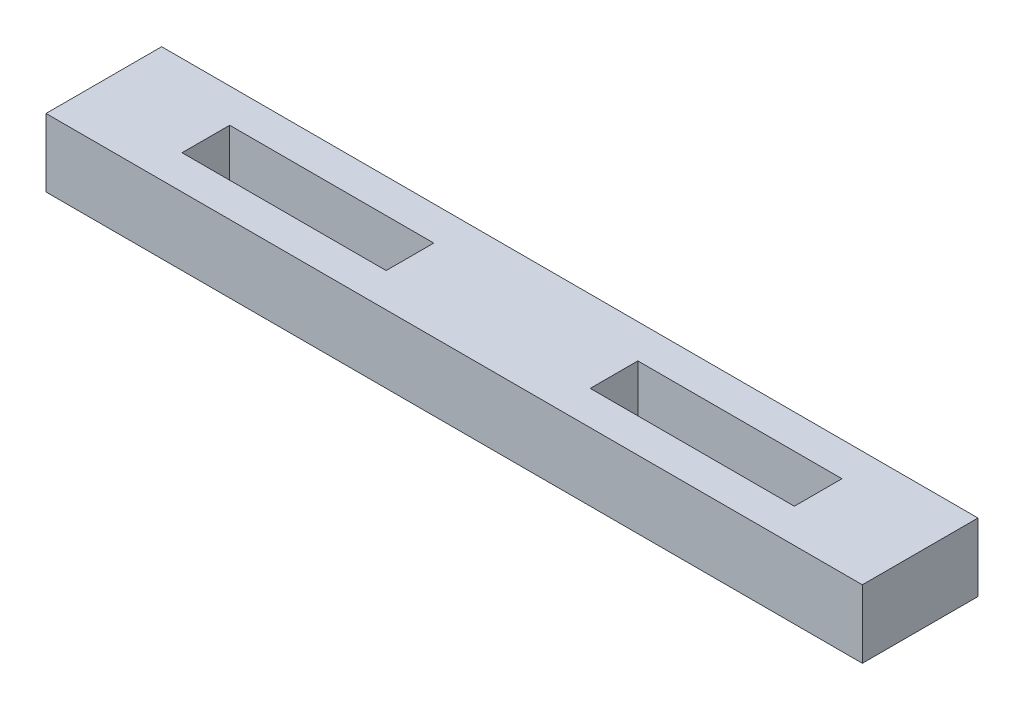
from build123d import *

# Parameters (mm, degrees)
SKETCH1_W               = 152.4
SKETCH1_H               = 21.59
BOSS_EXTRUDE1_DEPTH     = 12.7
SKETCH2_W               = 38.1
SKETCH2_H               = 8.89
CUT_EXTRUDE1_DEPTH      = 1
CUT_EXTRUDE1_DEPTH_BACK = 13.7


with BuildPart() as part:
    # Sketch1 → Boss-Extrude1 (new body)
    with BuildSketch(Plane(origin=(0, 0, 0), x_dir=(1, 0, 0), z_dir=(0, 1, 0))):
        with Locations((76.2, 10.795)):
            Rectangle(SKETCH1_W, SKETCH1_H)
    extrude(amount=BOSS_EXTRUDE1_DEPTH)

    # Sketch2 → Cut-Extrude1 (cut, two sides)
    with BuildSketch(Plane(origin=(0, 12.7, 0), x_dir=(1, 0, 0), z_dir=(0, 1, 0))) as cut_extrude1_sk:
        with Locations((38.1, 10.795)):
            Rectangle(SKETCH2_W, SKETCH2_H)
        with Locations((114.3, 10.795)):
            Rectangle(SKETCH2_W, SKETCH2_H)
    extrude(amount=CUT_EXTRUDE1_DEPTH, mode=Mode.SUBTRACT)
    extrude(cut_extrude1_sk.sketch, amount=-CUT_EXTRUDE1_DEPTH_BACK, mode=Mode.SUBTRACT)


solid = part.part
